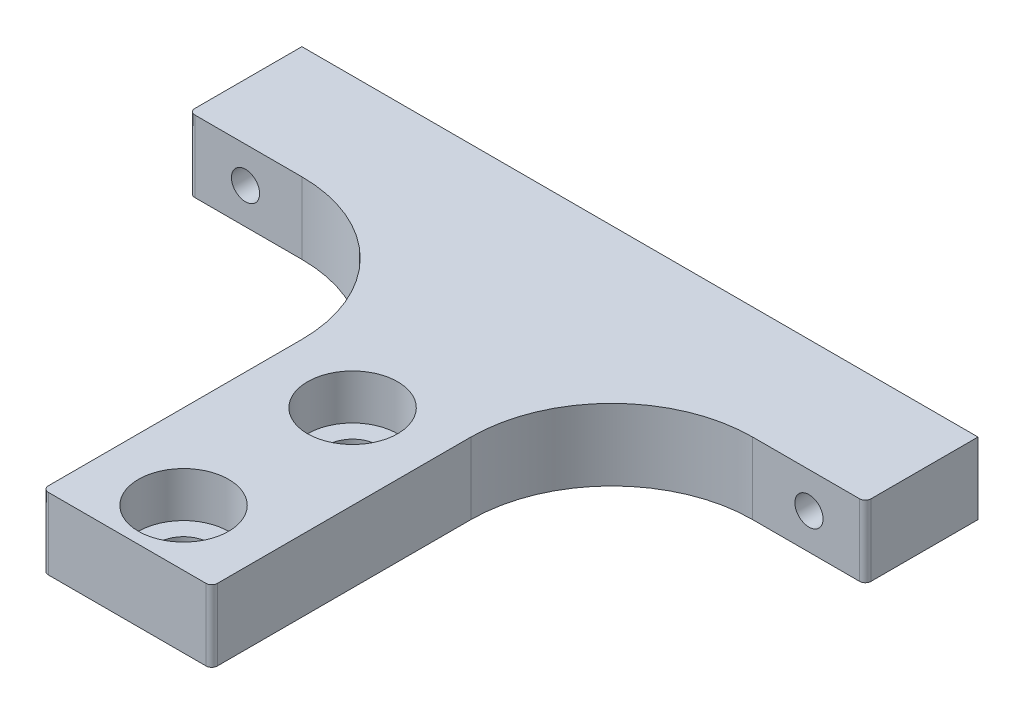
from build123d import *

# Parameters (mm, degrees)
BOSS_EXTRUDE1_DEPTH            = 6.35
FILLET1_R                      = 12.5
CBORE_FOR_M4_SHCS1_D           = 4.5
CBORE_FOR_M4_SHCS1_CBORE_D     = 8
CBORE_FOR_M4_SHCS1_CBORE_DEPTH = 4
M3X0_5_TAPPED_HOLE1_D          = 2.5
M3X0_5_TAPPED_HOLE1_DEPTH      = 10
FILLET2_R                      = 0.5
FILLET3_R                      = 0.5


with BuildPart() as part:
    # Sketch2 → Boss-Extrude1 (new body)
    with BuildSketch(Plane(origin=(0, 0, 0), x_dir=(1, 0, 0), z_dir=(0, 1, 0))):
        Polygon((-30, 0), (30, 0), (30, -10), (7.5, -10), (7.5, -45.5), (-7.5, -45.5), (-7.5, -10), (-30, -10), align=None)
    extrude(amount=BOSS_EXTRUDE1_DEPTH)

    # Fillet1
    fillet1_edges = [part.edges().sort_by_distance(p)[0] for p in [
        (-7.5, 3.175, 10),
        (7.5, 3.175, 10),
    ]]
    fillet(fillet1_edges, radius=FILLET1_R)

    # CBORE for M4 SHCS1 (through all)
    with Locations(Plane(origin=(0, 6.35, 0), x_dir=(1, 0, 0), z_dir=(0, 1, 0))):
        with Locations((0, -40.5), (0, -25.5)):
            CounterBoreHole(CBORE_FOR_M4_SHCS1_D / 2, CBORE_FOR_M4_SHCS1_CBORE_D / 2, CBORE_FOR_M4_SHCS1_CBORE_DEPTH)

    # M3x0.5 Tapped Hole1
    with Locations(Plane(origin=(0, 0, 0), x_dir=(-1, 0, 0), z_dir=(0, 0, -1))):
        with Locations((-25, 3.175), (25, 3.175)):
            Hole(M3X0_5_TAPPED_HOLE1_D / 2, depth=M3X0_5_TAPPED_HOLE1_DEPTH)

    # Fillet2
    fillet2_edges = [part.edges().sort_by_distance(p)[0] for p in [
        (-30, 3.175, 10),
        (30, 3.175, 10),
    ]]
    fillet(fillet2_edges, radius=FILLET2_R)

    # Fillet3
    fillet3_edges = [part.edges().sort_by_distance(p)[0] for p in [
        (7.5, 3.175, 45.5),
        (-7.5, 3.175, 45.5),
    ]]
    fillet(fillet3_edges, radius=FILLET3_R)


solid = part.part
